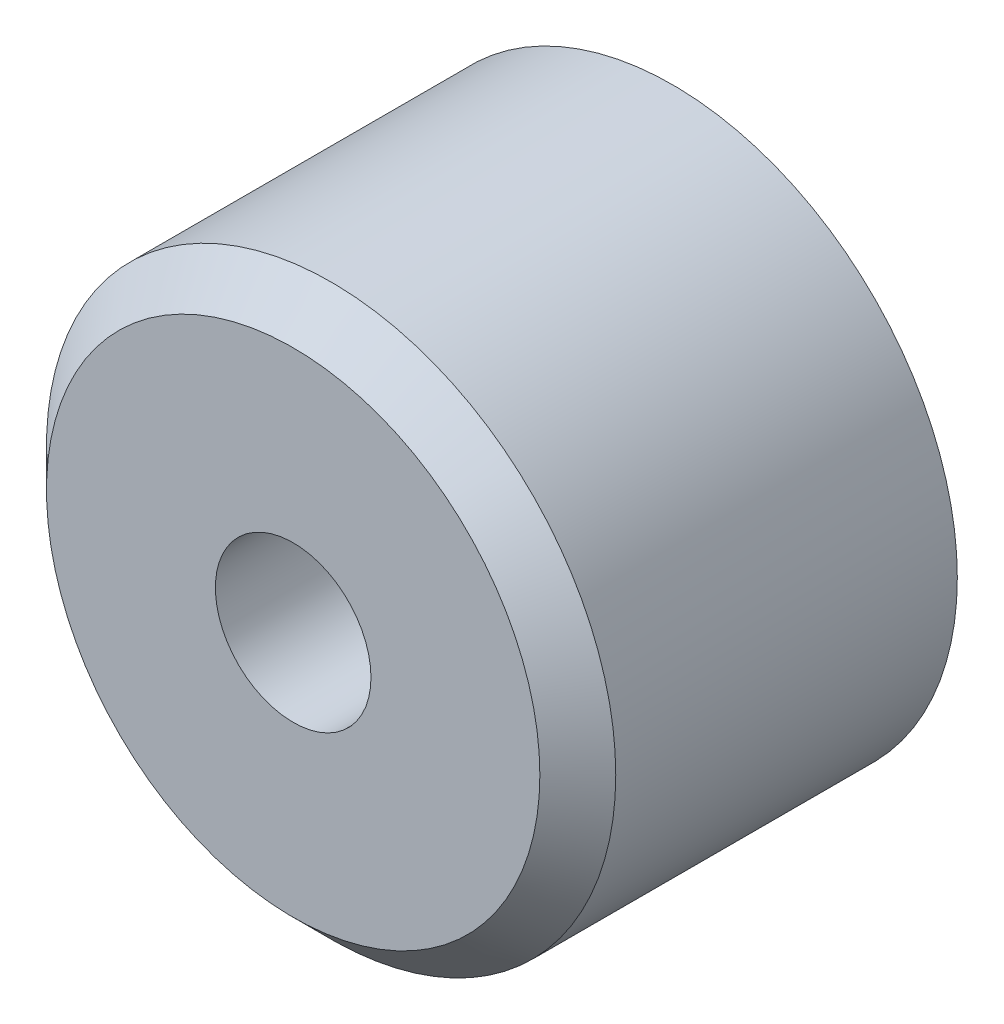
from build123d import *

# Parameters (mm, degrees)
ESQUISSE1_R        = 7.5
ESQUISSE1_R_2      = 5.05
BOSS_EXTRU_1_DEPTH = 1
ESQUISSE2_R        = 7.5
ESQUISSE2_R_2      = 2.05
BOSS_EXTRU_2_DEPTH = 9
CHANFREIN1_SIZE    = 1


with BuildPart() as part:
    # Esquisse1 → Boss.-Extru.1 (new body)
    with BuildSketch(Plane.XY):
        Circle(ESQUISSE1_R)
        Circle(ESQUISSE1_R_2, mode=Mode.SUBTRACT)
    extrude(amount=BOSS_EXTRU_1_DEPTH)

    # Esquisse2 → Boss.-Extru.2 (add)
    with BuildSketch(Plane.XY.offset(1)):
        Circle(ESQUISSE2_R)
        Circle(ESQUISSE2_R_2, mode=Mode.SUBTRACT)
    extrude(amount=BOSS_EXTRU_2_DEPTH)

    # Chanfrein1
    chanfrein1_edges = [part.edges().sort_by_distance(p)[0] for p in [
        (-7.5, 0, 10),
    ]]
    chamfer(chanfrein1_edges, length=CHANFREIN1_SIZE)


solid = part.part
